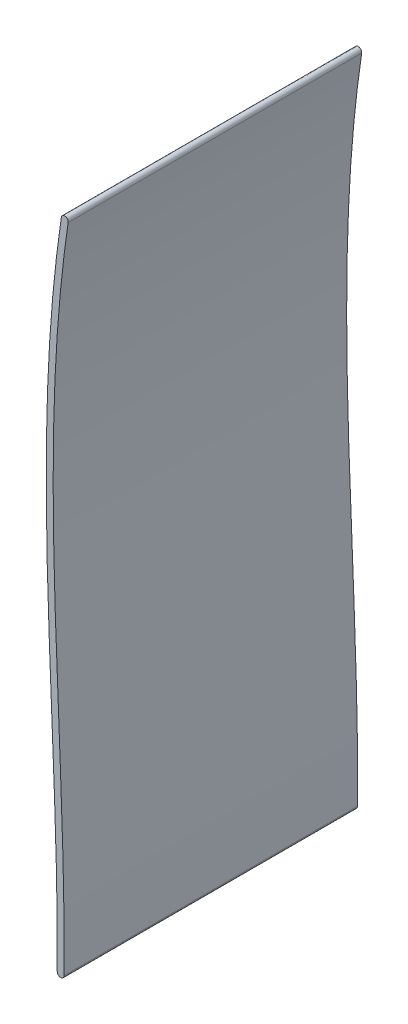
from build123d import *

# Parameters (mm, degrees)
BOSS_EXTRUDE1_DEPTH = 85


with BuildPart() as part:
    # Sketch1 → Boss-Extrude1 (new body)
    with BuildSketch(Plane.XY):
        with BuildLine():
            ThreePointArc((0, 0), (0.992728608, -1.007218899), (1.999947507, -0.014490291))
            add(Edge.make_bspline(
                [(1.999947507, -0.014490291), (2.114733526, 15.82825644), (1.206101992, 47.498374343), (-1.020828265, 95.047768028), (-1.485090195, 134.541376245), (0.232703186, 165.971459225), (2.001762336, 181.655093927), (3.160416359, 189.449723623)],
                knots=[0, 0, 0, 0, 0.25, 0.5, 0.75, 0.875, 1, 1, 1, 1], degree=3))
            ThreePointArc((3.160416359, 189.449723623), (2.318316835, 190.585887516), (1.182152942, 189.743787992))
            add(Edge.make_bspline(
                [(0, 0), (0.45722739, 63.106446464), (-8.16238637, 126.880135699), (1.182152942, 189.743787992)],
                knots=[0, 0, 0, 0, 1, 1, 1, 1], degree=3))
        make_face()
    extrude(amount=BOSS_EXTRUDE1_DEPTH)


solid = part.part
